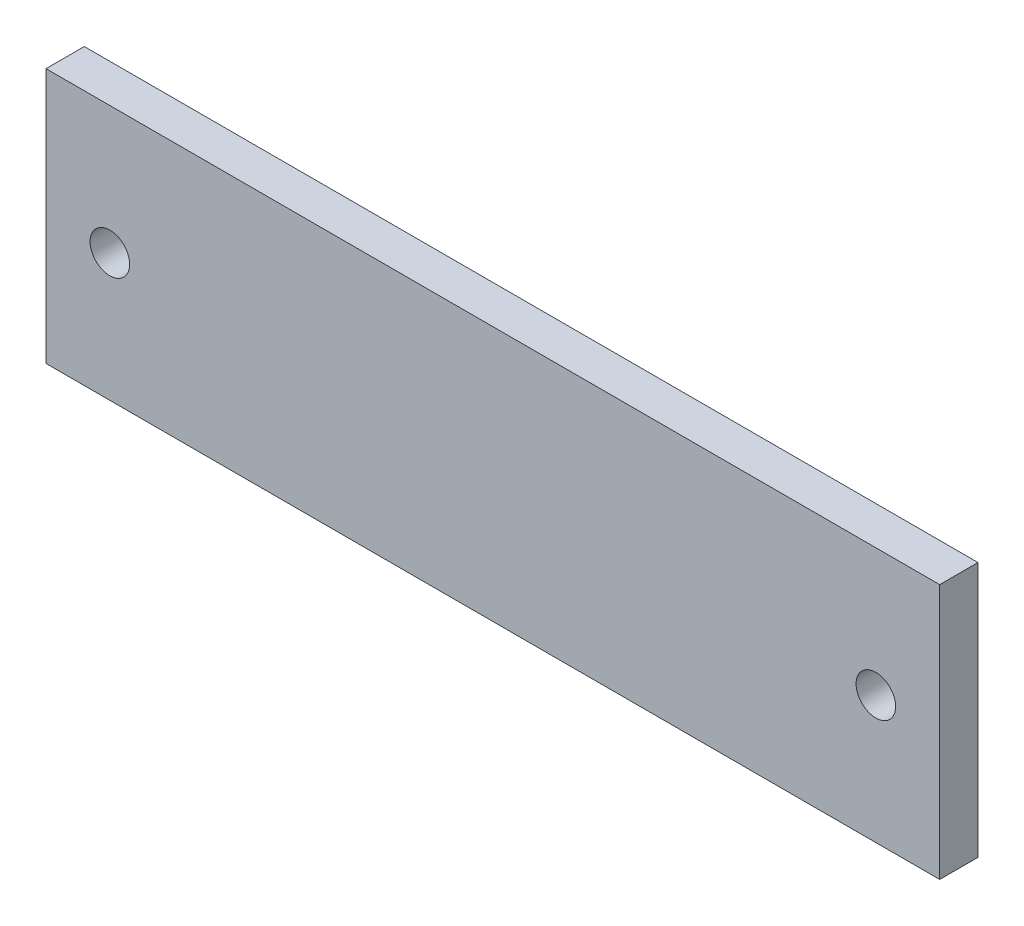
from build123d import *

# Parameters (mm, degrees)
SKETCH1_W           = 70
SKETCH1_H           = 20
SKETCH1_R           = 1.55
BOSS_EXTRUDE1_DEPTH = 3


with BuildPart() as part:
    # Sketch1 → Boss-Extrude1 (new body)
    with BuildSketch(Plane.XY):
        Rectangle(SKETCH1_W, SKETCH1_H)
        with Locations((30, 0)):
            Circle(SKETCH1_R, mode=Mode.SUBTRACT)
        with Locations((-30, 0)):
            Circle(SKETCH1_R, mode=Mode.SUBTRACT)
    extrude(amount=BOSS_EXTRUDE1_DEPTH)


solid = part.part
